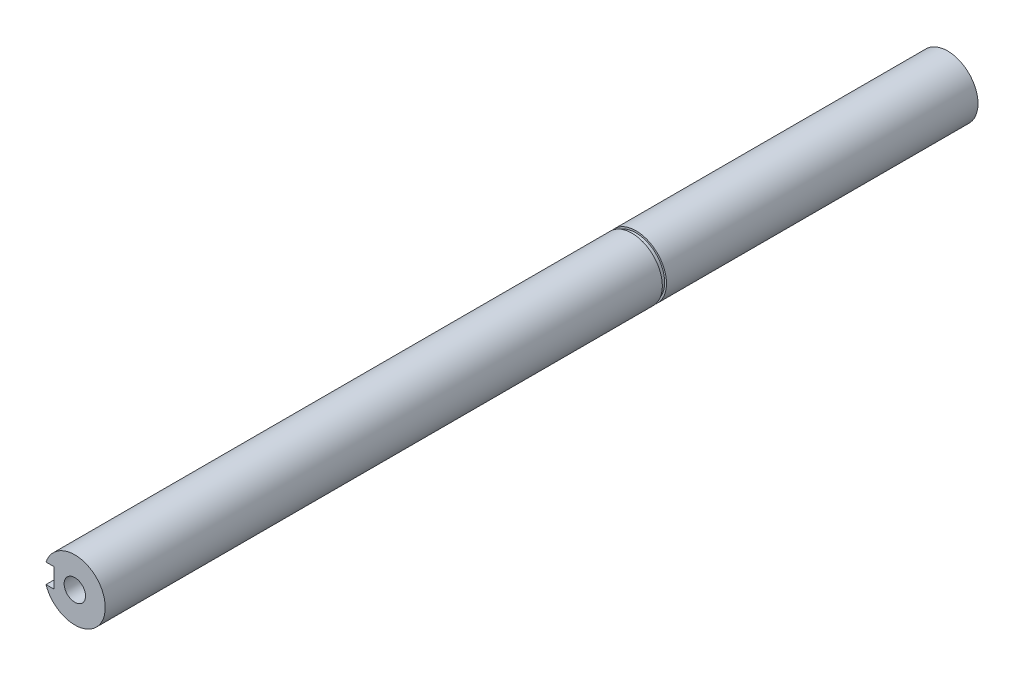
from build123d import *

# Parameters (mm, degrees)
SKETCH_1_R          = 12.5
EXTRUDE_1_DEPTH     = 358.6
CUT_EXTRUDE_START   = -30
SKETCH_2_W          = 8
SKETCH_2_H          = 8
CUT_EXTRUDE_1_DEPTH = 30
SKETCH_3_R          = 26
SKETCH_3_R_2        = 11.75
CUT_EXTRUDE_2_DEPTH = 1.7
CUT_EXTRUDE_START_2 = -128
SKETCH_4_W          = 8
SKETCH_4_H          = 8
CUT_EXTRUDE_3_DEPTH = 128
M10X1_252_D         = 8.8
M10X1_252_DEPTH     = 32.5
M10X1_252_TIP       = 2.643786724
M10X1_253_D         = 8.8
M10X1_253_DEPTH     = 32.5
M10X1_253_TIP       = 2.643786724


with BuildPart() as part:
    # Эскиз1 → Бобышка-Вытянуть1 (new body)
    with BuildSketch(Plane.XY):
        with Locations((0, -291.807573628)):
            Circle(SKETCH_1_R)
    extrude(amount=-EXTRUDE_1_DEPTH)

    # Эскиз2 → Вырез-Вытянуть1 (cut)
    with BuildSketch(Plane.XY.offset(CUT_EXTRUDE_START)):
        with Locations((-12.5, -291.807573628)):
            Rectangle(SKETCH_2_W, SKETCH_2_H)
    extrude(amount=CUT_EXTRUDE_1_DEPTH, mode=Mode.SUBTRACT)

    # Эскиз3 → Вырез-Вытянуть2 (cut)
    with BuildSketch(Plane(origin=(0, 0, -230.6), x_dir=(-1, 0, 0), z_dir=(0, 0, -1))):
        with Locations((0, -291.807573628)):
            Circle(SKETCH_3_R)
        with Locations((0, -291.807573628)):
            Circle(SKETCH_3_R_2, mode=Mode.SUBTRACT)
    extrude(amount=-CUT_EXTRUDE_2_DEPTH, mode=Mode.SUBTRACT)

    # Эскиз4 → Вырез-Вытянуть3 (cut)
    with BuildSketch(Plane(origin=(0, 0, -358.6), x_dir=(-1, 0, 0), z_dir=(0, 0, -1)).offset(CUT_EXTRUDE_START_2)):
        with Locations((12.5, -291.807573628)):
            Rectangle(SKETCH_4_W, SKETCH_4_H)
    extrude(amount=CUT_EXTRUDE_3_DEPTH, mode=Mode.SUBTRACT)

    # Сверление под метчик M10x1.252
    with Locations(Plane.XY):
        with Locations((0, -291.807573628)):
            Hole(M10X1_252_D / 2, depth=M10X1_252_DEPTH)
            with Locations((0, 0, -(M10X1_252_DEPTH + M10X1_252_TIP / 2))):  # 118° drill point
                Cone(0, M10X1_252_D / 2, M10X1_252_TIP, mode=Mode.SUBTRACT)

    # Сверление под метчик M10x1.253
    with Locations(Plane(origin=(0, 0, -358.6), x_dir=(-1, 0, 0), z_dir=(0, 0, -1))):
        with Locations((0, -291.807573628)):
            Hole(M10X1_253_D / 2, depth=M10X1_253_DEPTH)
            with Locations((0, 0, -(M10X1_253_DEPTH + M10X1_253_TIP / 2))):  # 118° drill point
                Cone(0, M10X1_253_D / 2, M10X1_253_TIP, mode=Mode.SUBTRACT)


solid = part.part
